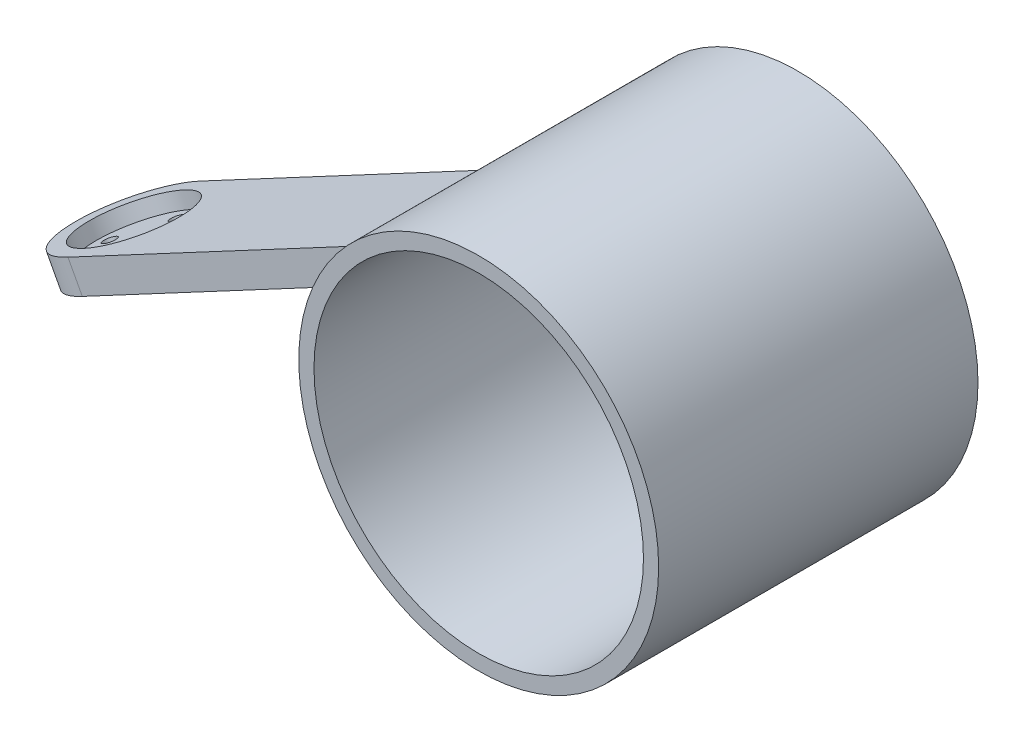
from build123d import *

# Parameters (mm, degrees)
SKETCH1_R                = 35.5
SKETCH1_R_2              = 32.5
BOSS_EXTRUDE1_DEPTH      = 63
SKETCH2_R                = 32.5
BOSS_EXTRUDE2_DEPTH      = 3
BOSS_EXTRUDE6_DEPTH      = 14.275
BOSS_EXTRUDE6_DEPTH_BACK = 11.725
SKETCH7_R                = 13
BOSS_EXTRUDE7_DEPTH      = 6
SKETCH8_R                = 10
CUT_EXTRUDE1_DEPTH       = 3
SKETCH9_R                = 1.275
CUT_EXTRUDE2_DEPTH       = 67.65770114


with BuildPart() as part:
    # Sketch1 → Boss-Extrude1 (new body)
    with BuildSketch(Plane.XY):
        Circle(SKETCH1_R)
        Circle(SKETCH1_R_2, mode=Mode.SUBTRACT)
    extrude(amount=BOSS_EXTRUDE1_DEPTH)

    # Sketch2 → Boss-Extrude2 (add)
    with BuildSketch(Plane(origin=(0, 0, 0), x_dir=(-1, 0, 0), z_dir=(0, 0, -1))):
        Circle(SKETCH2_R)
    extrude(amount=-BOSS_EXTRUDE2_DEPTH)

    # Sketch6 → Boss-Extrude6 (add, two sides)
    with BuildSketch(Plane.XY.offset(26.896958138)) as boss_extrude6_sk:
        with BuildLine():
            Line((-34.208935101, 9.486767586), (-102.85732032, -27.128564879))
            Line((-102.85732032, -27.128564879), (-100.033619175, -32.422590931))
            Line((-100.033619175, -32.422590931), (-35.441970042, 2.028979924))
            ThreePointArc((-35.441970042, 2.028979924), (-35.024517071, 5.790786127), (-34.208935101, 9.486767586))
        make_face()
    extrude(amount=BOSS_EXTRUDE6_DEPTH)
    extrude(boss_extrude6_sk.sketch, amount=-BOSS_EXTRUDE6_DEPTH_BACK)

    # Sketch7 → Boss-Extrude7 (add)
    with BuildSketch(Plane(origin=(-8.692215236, 16.296630393, 0), x_dir=(0.882337675, 0.470616858, 0), z_dir=(0.470616858, -0.882337675, 0))):
        with Locations((-103.522048859, 28.171958138)):
            Circle(SKETCH7_R)
    extrude(amount=-BOSS_EXTRUDE7_DEPTH)

    # Sketch8 → Cut-Extrude1 (cut)
    with BuildSketch(Plane(origin=(-11.515916381, 21.590656445, 0), x_dir=(0.882337675, 0.470616858, 0), z_dir=(-0.470616858, 0.882337675, 0))):
        with Locations((-103.522048859, -28.171958138)):
            Circle(SKETCH8_R)
    extrude(amount=-CUT_EXTRUDE1_DEPTH, mode=Mode.SUBTRACT)

    # Sketch9 → Cut-Extrude2 (cut, through all)
    with BuildSketch(Plane(origin=(-8.692215236, 16.296630393, 0), x_dir=(0.882337675, 0.470616858, 0), z_dir=(0.470616858, -0.882337675, 0))):
        with Locations((-103.522048859, 35.171958138)):
            Circle(SKETCH9_R)
        with Locations((-110.522048859, 28.171958138)):
            Circle(SKETCH9_R)
        with Locations((-96.522048859, 28.171958138)):
            Circle(SKETCH9_R)
        with Locations((-103.522048859, 21.171958138)):
            Circle(SKETCH9_R)
    extrude(amount=-CUT_EXTRUDE2_DEPTH, mode=Mode.SUBTRACT)


solid = part.part
